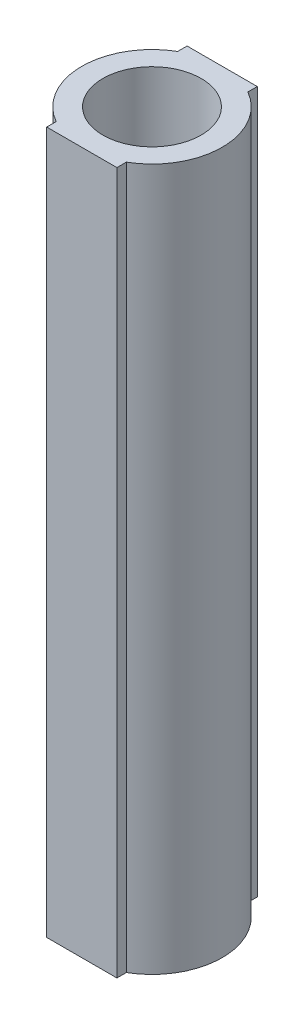
from build123d import *

# Parameters (mm, degrees)
SKETCH1_R           = 10
SKETCH1_R_2         = 7
BOSS_EXTRUDE1_DEPTH = 100
BOSS_EXTRUDE2_DEPTH = 100


with BuildPart() as part:
    # Sketch1 → Boss-Extrude1 (new body)
    with BuildSketch(Plane(origin=(0, 0, 0), x_dir=(1, 0, 0), z_dir=(0, 1, 0))):
        Circle(SKETCH1_R)
        Circle(SKETCH1_R_2, mode=Mode.SUBTRACT)
    extrude(amount=BOSS_EXTRUDE1_DEPTH)

    # Sketch2 → Boss-Extrude2 (add)
    with BuildSketch(Plane(origin=(0, 100, 0), x_dir=(1, 0, 0), z_dir=(0, 1, 0))):
        with BuildLine():
            Line((0, 10), (-5, 10))
            Line((-5, 10), (-5, 8.660254038))
            ThreePointArc((-5, 8.660254038), (-2.588190451, 9.659258263), (0, 10))
        make_face()
        with BuildLine():
            Line((5, 10), (0, 10))
            ThreePointArc((0, 10), (2.588190451, 9.659258263), (5, 8.660254038))
            Line((5, 8.660254038), (5, 10))
        make_face()
        with BuildLine():
            ThreePointArc((-1.3e-08, -10), (-2.588190457, -9.659258261), (-5, -8.660254038))
            Line((-5, -8.660254038), (-5, -10))
            Line((-5, -10), (-1.3e-08, -10))
        make_face()
        with BuildLine():
            Line((5, -10), (5, -8.660254038))
            ThreePointArc((5, -8.660254038), (2.588190445, -9.659258265), (-1.3e-08, -10))
            Line((-1.3e-08, -10), (5, -10))
        make_face()
    extrude(amount=-BOSS_EXTRUDE2_DEPTH)


solid = part.part
